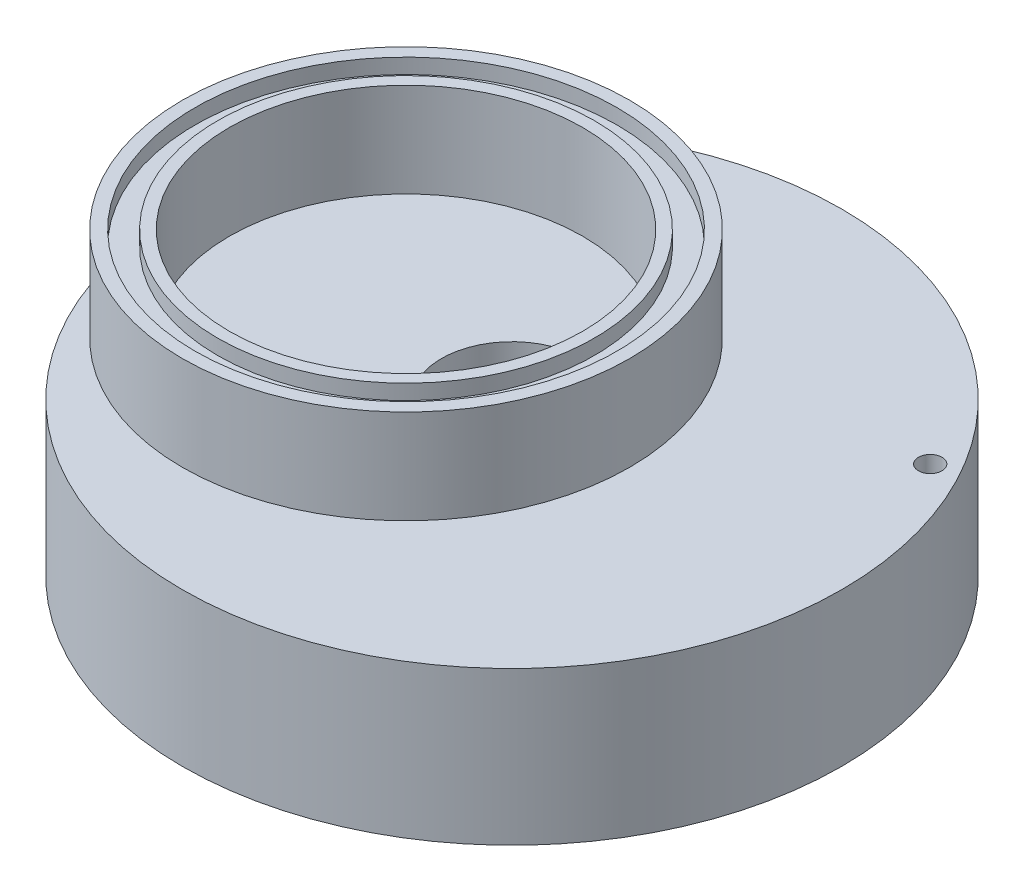
from build123d import *

# Parameters (mm, degrees)
SKETCH2_R                        = 30.1625
SKETCH2_R_2                      = 23.8125
BOSS_EXTRUDE1_DEPTH              = 12.7
SKETCH4_R                        = 28.448
SKETCH4_R_2                      = 25.4
CUT_EXTRUDE1_DEPTH               = 2.032
F_1_8_0_125_DIAMETER_HOLE1_D     = 3.175
F_1_8_0_125_DIAMETER_HOLE1_DEPTH = 6.35
F_1_8_0_125_DIAMETER_HOLE1_TIP   = 0.953866233
F_1_8_0_125_DIAMETER_HOLE2_D     = 3.175
F_1_8_0_125_DIAMETER_HOLE2_DEPTH = 6.35
F_1_8_0_125_DIAMETER_HOLE2_TIP   = 0.953866233


with BuildPart() as part:
    # Sketch1 → Revolve1 (revolve)
    with BuildSketch(Plane.XY):
        Polygon((-9.525, -6.35), (-9.525, 0), (-44.45, 0), (-44.45, -20.6375), (-36.3855, -20.6375), (-36.3855, -18.6055), (-33.3375, -18.6055), (-33.3375, -20.6375), (-31.75, -20.6375), (-31.75, -19.05), (-15.875, -6.35), align=None)
    revolve(axis=Axis((0, 0, 0), (0, 1, 0)))

    # Sketch2 → Boss-Extrude1 (add)
    with BuildSketch(Plane(origin=(0, 0, 0), x_dir=(1, 0, 0), z_dir=(0, 1, 0))):
        with Locations((-14.2875, 0)):
            Circle(SKETCH2_R)
        with Locations((-14.2875, 0)):
            Circle(SKETCH2_R_2, mode=Mode.SUBTRACT)
    extrude(amount=BOSS_EXTRUDE1_DEPTH)

    # Sketch4 → Cut-Extrude1 (cut)
    with BuildSketch(Plane(origin=(0, 12.7, 0), x_dir=(1, 0, 0), z_dir=(0, 1, 0))):
        with Locations((-14.2875, 0)):
            Circle(SKETCH4_R)
        with Locations((-14.2875, 0)):
            Circle(SKETCH4_R_2, mode=Mode.SUBTRACT)
    extrude(amount=-CUT_EXTRUDE1_DEPTH, mode=Mode.SUBTRACT)

    # 1/8 (0.125) Diameter Hole1
    with Locations(Plane(origin=(0, -20.6375, 0), x_dir=(-1, 0, 0), z_dir=(0, -1, 0))):
        with Locations((-41.275, 0)):
            Hole(F_1_8_0_125_DIAMETER_HOLE1_D / 2, depth=F_1_8_0_125_DIAMETER_HOLE1_DEPTH)
            with Locations((0, 0, -(F_1_8_0_125_DIAMETER_HOLE1_DEPTH + F_1_8_0_125_DIAMETER_HOLE1_TIP / 2))):  # 118° drill point
                Cone(0, F_1_8_0_125_DIAMETER_HOLE1_D / 2, F_1_8_0_125_DIAMETER_HOLE1_TIP, mode=Mode.SUBTRACT)

    # 1/8 (0.125) Diameter Hole2
    with Locations(Plane(origin=(0, 0, 0), x_dir=(1, 0, 0), z_dir=(0, 1, 0))):
        with Locations((35.745198541, 20.6375)):
            Hole(F_1_8_0_125_DIAMETER_HOLE2_D / 2, depth=F_1_8_0_125_DIAMETER_HOLE2_DEPTH)
            with Locations((0, 0, -(F_1_8_0_125_DIAMETER_HOLE2_DEPTH + F_1_8_0_125_DIAMETER_HOLE2_TIP / 2))):  # 118° drill point
                Cone(0, F_1_8_0_125_DIAMETER_HOLE2_D / 2, F_1_8_0_125_DIAMETER_HOLE2_TIP, mode=Mode.SUBTRACT)


solid = part.part
